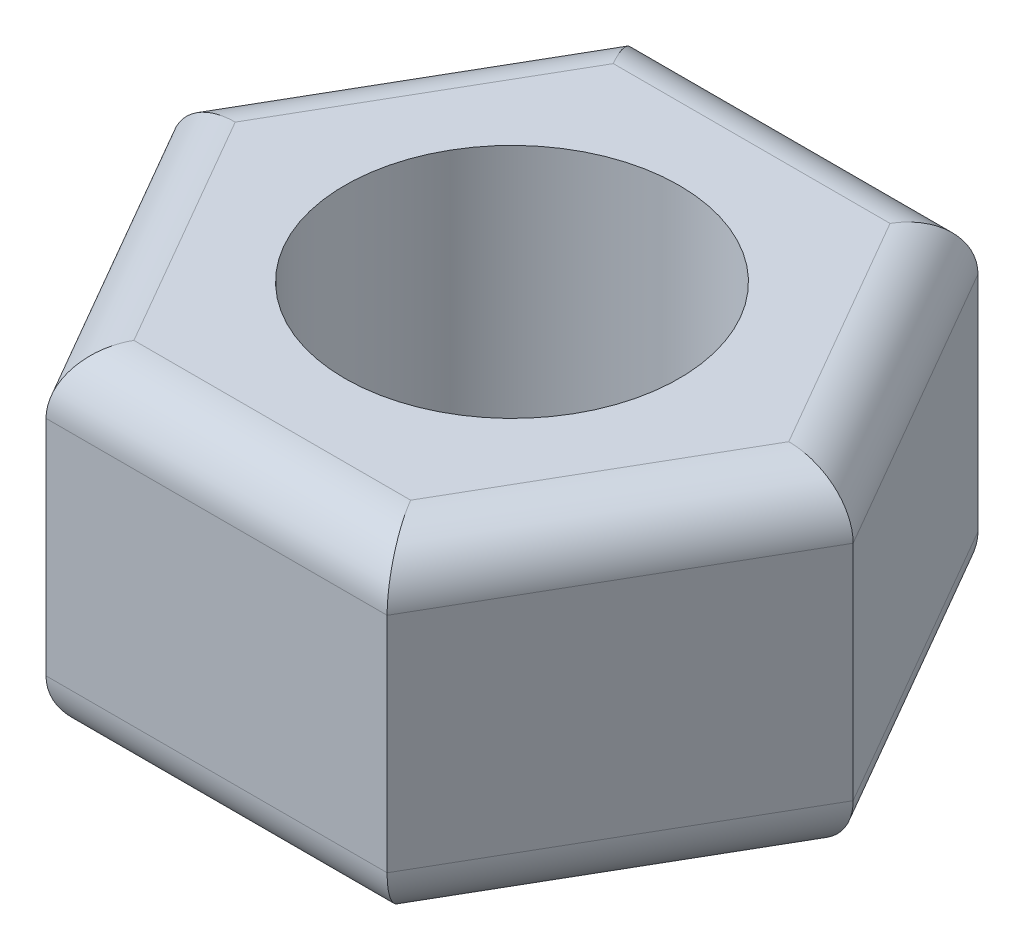
from build123d import *

# Parameters (mm, degrees)
EXTRUDE_1_DEPTH     = 3
SKETCH_2_R          = 1.5
CUT_EXTRUDE_1_DEPTH = 3
FILLET_1_R          = 0.5


with BuildPart() as part:
    # 草图1 → 凸台-拉伸1 (new body)
    with BuildSketch(Plane(origin=(0, 0, 0), x_dir=(1, 0, 0), z_dir=(0, 1, 0))):
        Polygon((3.059956427, 0), (1.529978213, 2.65), (-1.529978213, 2.65), (-3.059956427, 0), (-1.529978213, -2.65), (1.529978213, -2.65), align=None)
    extrude(amount=EXTRUDE_1_DEPTH)

    # 草图2 → 切除-拉伸1 (cut)
    with BuildSketch(Plane(origin=(0, 3, 0), x_dir=(1, 0, 0), z_dir=(0, 1, 0))):
        Circle(SKETCH_2_R)
    extrude(amount=-CUT_EXTRUDE_1_DEPTH, mode=Mode.SUBTRACT)

    # 圆角1
    fillet_1_edges = [part.edges().sort_by_distance(p)[0] for p in [
        (0, 3, -2.65),
        (-2.29496732, 3, -1.325),
        (-2.29496732, 3, 1.325),
        (0, 3, 2.65),
        (2.29496732, 3, 1.325),
        (0, 0, 2.65),
        (-2.29496732, 0, 1.325),
        (-2.29496732, 0, -1.325),
        (2.29496732, 3, -1.325),
        (0, 0, -2.65),
        (2.29496732, 0, -1.325),
        (2.29496732, 0, 1.325),
    ]]
    fillet(fillet_1_edges, radius=FILLET_1_R)


solid = part.part
